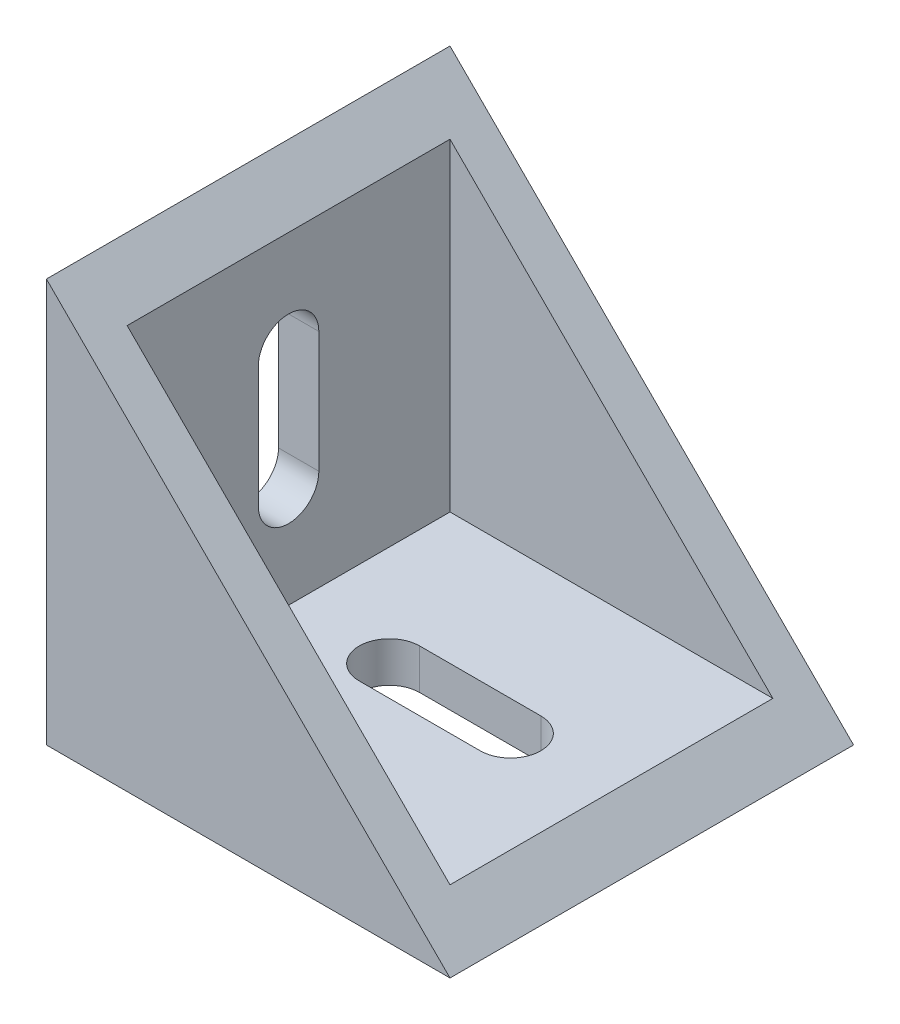
from build123d import *

# Parameters (mm, degrees)
BOSS_EXTRUDE1_DEPTH = 20
SHELL1_T            = -2
CUT_EXTRUDE1_DEPTH  = 20
CUT_EXTRUDE2_DEPTH  = 20


with BuildPart() as part:
    # Sketch1 → Boss-Extrude1 (new body)
    with BuildSketch(Plane.XY):
        Polygon((-10, 10), (10, -10), (-10, -10), align=None)
    extrude(amount=BOSS_EXTRUDE1_DEPTH)

    # Shell1
    shell1_openings = [part.faces().sort_by_distance(p)[0] for p in [
        (0, 0, 10),
    ]]
    offset(amount=SHELL1_T, openings=shell1_openings, kind=Kind.INTERSECTION)

    # Sketch2 → Cut-Extrude1 (cut)
    with BuildSketch(Plane(origin=(-8, 0, 0), x_dir=(0, 0, -1), z_dir=(1, 0, 0))):
        with BuildLine():
            Line((-11.5, 3), (-11.5, -3))
            ThreePointArc((-11.5, -3), (-10, -4.5), (-8.5, -3))
            Line((-8.5, -3), (-8.5, 3))
            ThreePointArc((-8.5, 3), (-10, 4.5), (-11.5, 3))
        make_face()
    extrude(amount=-CUT_EXTRUDE1_DEPTH, mode=Mode.SUBTRACT)

    # Sketch3 → Cut-Extrude2 (cut)
    with BuildSketch(Plane(origin=(0, -8, 0), x_dir=(1, 0, 0), z_dir=(0, 1, 0))):
        with BuildLine():
            Line((-3, -8.5), (3, -8.5))
            ThreePointArc((3, -8.5), (4.5, -10), (3, -11.5))
            Line((3, -11.5), (-3, -11.5))
            ThreePointArc((-3, -11.5), (-4.5, -10), (-3, -8.5))
        make_face()
    extrude(amount=-CUT_EXTRUDE2_DEPTH, mode=Mode.SUBTRACT)


solid = part.part
